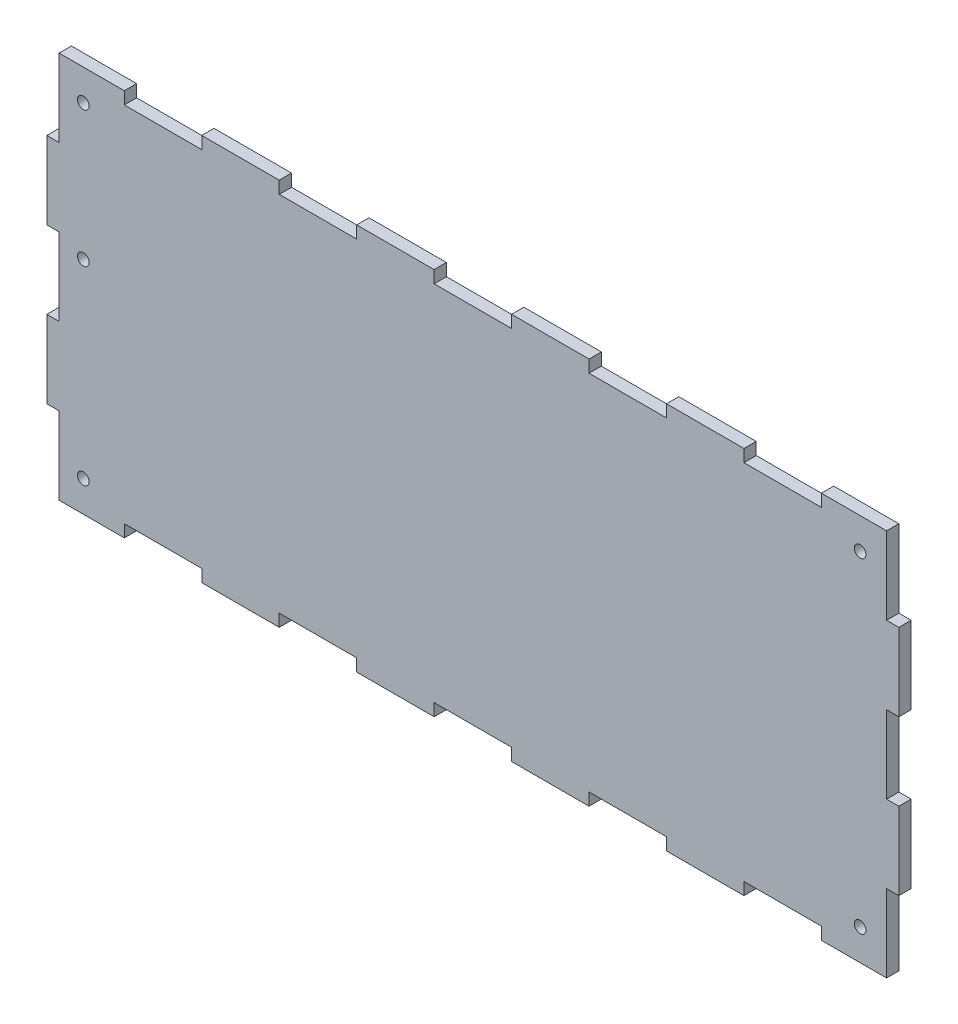
from build123d import *

# Parameters (mm, degrees)
SKETCH51_W           = 220
SKETCH51_H           = 99.999981374
SKETCH51_R           = 1.5
BOSS_EXTRUDE13_DEPTH = 3.175
SKETCH52_W           = 3.175
SKETCH52_H           = 20
SKETCH52_W_2         = 20
SKETCH52_H_2         = 3.175
CUT_EXTRUDE25_DEPTH  = 3.175


with BuildPart() as part:
    # Sketch51 → Boss-Extrude13 (new body)
    with BuildSketch(Plane(origin=(0, 0, 0), x_dir=(-1, 0, 0), z_dir=(0, 0, -1))):
        with Locations((4.414e-06, 4.4643e-05)):
            Rectangle(SKETCH51_W, SKETCH51_H)
        with Locations((100.587627215, -41.999946044)):
            Circle(SKETCH51_R, mode=Mode.SUBTRACT)
        with Locations((100.587627215, 42.00003533)):
            Circle(SKETCH51_R, mode=Mode.SUBTRACT)
        with Locations((-99.9999958, -41.999946044)):
            Circle(SKETCH51_R, mode=Mode.SUBTRACT)
        with Locations((-99.9999958, 42.00003533)):
            Circle(SKETCH51_R, mode=Mode.SUBTRACT)
        with Locations((100.587627215, 7.000053956)):
            Circle(SKETCH51_R, mode=Mode.SUBTRACT)
    extrude(amount=BOSS_EXTRUDE13_DEPTH)

    # Sketch52 → Cut-Extrude25 (cut)
    with BuildSketch(Plane(origin=(0, 0, -3.175), x_dir=(-1, 0, 0), z_dir=(0, 0, -1))):
        with Locations((108.4125042, 3.533e-05)):
            Rectangle(SKETCH52_W, SKETCH52_H)
        with Locations((108.4125042, 40.00003533)):
            Rectangle(SKETCH52_W, SKETCH52_H)
        with Locations((108.4125042, -39.99996467)):
            Rectangle(SKETCH52_W, SKETCH52_H)
        with Locations((-108.4124958, 3.533e-05)):
            Rectangle(SKETCH52_W, SKETCH52_H)
        with Locations((-108.4124958, 40.00003533)):
            Rectangle(SKETCH52_W, SKETCH52_H)
        with Locations((-108.4124958, -39.99996467)):
            Rectangle(SKETCH52_W, SKETCH52_H)
        with Locations((40.0000042, 48.41253533)):
            Rectangle(SKETCH52_W_2, SKETCH52_H_2)
        with Locations((80.0000042, 48.41253533)):
            Rectangle(SKETCH52_W_2, SKETCH52_H_2)
        with Locations((4.2e-06, 48.41253533)):
            Rectangle(SKETCH52_W_2, SKETCH52_H_2)
        with Locations((-39.9999958, 48.41253533)):
            Rectangle(SKETCH52_W_2, SKETCH52_H_2)
        with Locations((-79.9999958, 48.41253533)):
            Rectangle(SKETCH52_W_2, SKETCH52_H_2)
        with Locations((40.0000042, -48.412446044)):
            Rectangle(SKETCH52_W_2, SKETCH52_H_2)
        with Locations((80.0000042, -48.412446044)):
            Rectangle(SKETCH52_W_2, SKETCH52_H_2)
        with Locations((4.2e-06, -48.412446044)):
            Rectangle(SKETCH52_W_2, SKETCH52_H_2)
        with Locations((-39.9999958, -48.412446044)):
            Rectangle(SKETCH52_W_2, SKETCH52_H_2)
        with Locations((-79.9999958, -48.412446044)):
            Rectangle(SKETCH52_W_2, SKETCH52_H_2)
    extrude(amount=-CUT_EXTRUDE25_DEPTH, mode=Mode.SUBTRACT)


solid = part.part
